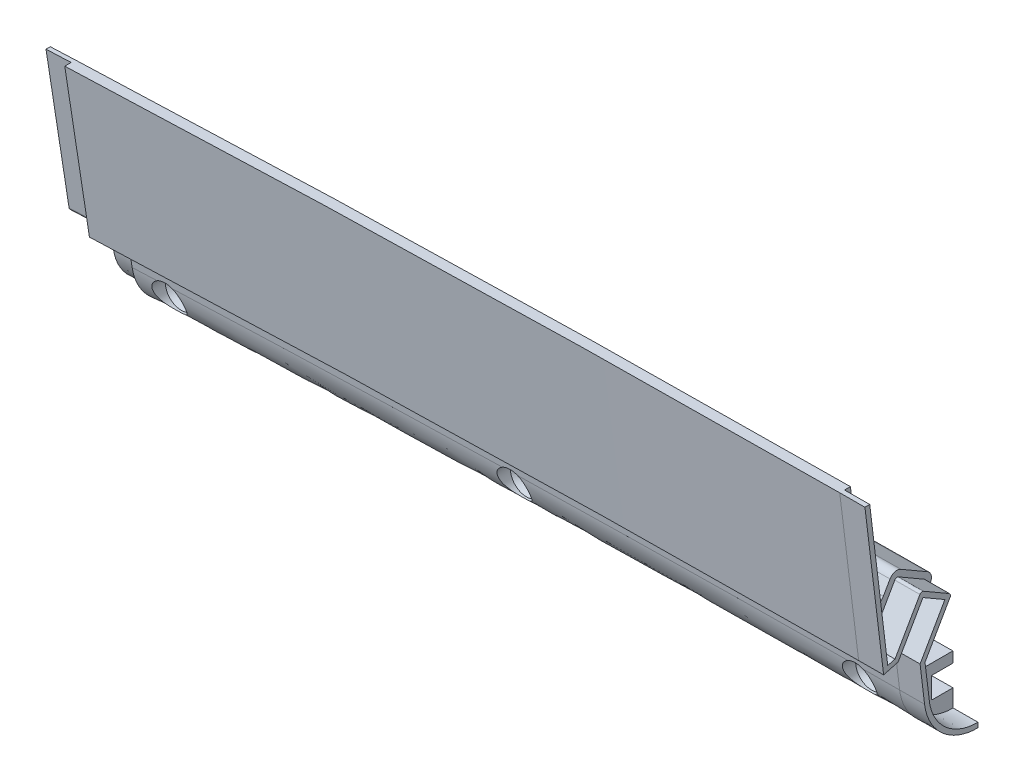
from build123d import *


with BuildPart() as part:
    # Sweep3: sweep along a path in Sketch3
    with BuildLine(Plane.XY.offset(101.6)) as sweep3_path:
        ThreePointArc((622.103936151, -83.199836272), (0, -43.636564626), (-622.103936151, -83.199836272))
    # Sketch4 → Sweep3 (sweep)
    with BuildSketch(Plane(origin=(-117.330566703, 4.430423936, 1117.6), x_dir=(0, 0, -1), z_dir=(0.9994536405585157, 0.03305178322465143, 0))):
        with BuildLine():
            Line((991.529482971, -5.453775083), (988.971801376, -5.453775083))
            Line((988.971801376, -5.453775083), (993.32506615, -42.283775083))
            Line((993.32506615, -42.283775083), (996.794703229, -41.354088728))
            Line((996.794703229, -41.354088728), (1002.763703229, -31.015013775))
            Line((1002.763703229, -31.015013775), (1007.999, -34.037749136))
            Line((1007.999, -34.037749136), (1002.03, -44.376824659))
            Line((1002.03, -44.376824659), (1003.077032208, -53.235049058))
            ThreePointArc((1003.077032208, -53.235049058), (1007.29752688, -61.276835992), (1015.8095, -64.443731312))
            Line((1015.8095, -64.443731312), (1015.8095, -59.12218153))
            Line((1015.8095, -59.12218153), (1010.7295, -59.12218153))
            Line((1010.7295, -59.12218153), (1010.7295, -54.041969025))
            Line((1010.7295, -54.041969025), (1015.8095, -54.041969025))
            Line((1015.8095, -54.041969025), (1015.8095, -51.501969025))
            Line((1015.8095, -51.501969025), (1007.687322123, -51.501969025))
            ThreePointArc((1007.687322123, -51.501969025), (1005.99997215, -50.860507955), (1005.164881483, -49.260118685))
            Line((1005.164881483, -49.260118685), (1004.750455768, -45.75394576))
            ThreePointArc((1004.750455768, -45.75394576), (1004.7850335, -44.943801809), (1005.073167189, -44.18583887))
            Line((1005.073167189, -44.18583887), (1010.516206197, -34.757795418))
            ThreePointArc((1010.516206197, -34.757795418), (1010.706497969, -33.312277166), (1009.818941274, -32.155567572))
            Line((1009.818941274, -32.155567572), (1003.483804566, -28.49781089))
            ThreePointArc((1003.483804566, -28.49781089), (1002.038222268, -28.307482122), (1000.881475684, -29.195102853))
            Line((1000.881475684, -29.195102853), (999.272416391, -31.982200293))
            ThreePointArc((999.272416391, -31.982200293), (996.560692883, -33.200105913), (994.550246564, -31.010392672))
            Line((994.550246564, -31.010392672), (991.529482971, -5.453775083))
        make_face()
    sweep(path=sweep3_path.line)

    # SurfaceCut1
    split(bisect_by=Plane(origin=(-207.689397228, -8.721580716, 0), x_dir=(0.04195640690671103, -0.9991194422687804, 0), z_dir=(-0.9991194422687804, -0.04195640690671103, 0)), keep=Keep.BOTTOM)

    # SurfaceCut2
    split(bisect_by=Plane(origin=(-22.599527872, -0.103088244, 0), x_dir=(-0.00456147456524855, 0.9999895964207781, 0), z_dir=(0.9999895964207781, 0.00456147456524855, 0)), keep=Keep.BOTTOM)

    # Sketch8 → Cut-Revolve1 (revolve, cut)
    with BuildSketch(Plane(origin=(-117.056038996, -3.871025798, 0), x_dir=(0, 0, -1), z_dir=(0.9994536405585157, 0.03305178322465143, 0)), mode=Mode.PRIVATE) as cut_revolve1_sk:
        Polygon((-119.5705, -48.27608749), (-106.8705, -48.27608749), (-106.8705, -46.37108749), (-108.7755, -46.37108749), (-110.6805, -44.46608749), (-119.5705, -44.46608749), align=None)
    cut_revolve1 = revolve(cut_revolve1_sk.sketch.rotate(Axis((-115.460428217, -52.120737191, 119.5705), (0, 0, -1)), 91.894072645), axis=Axis((-115.460428217, -52.120737191, 119.5705), (0, 0, -1)), mode=Mode.SUBTRACT)

    # Sketch-Pattern1: Cut-Revolve1 at 2 more places
    with Locations((82.543476, 1.248991, 0), (-82.510753, -2.638363, 0)):
        add(cut_revolve1, mode=Mode.SUBTRACT)

    # Sweep4: sweep along a path in Sketch12
    with BuildLine(Plane(origin=(0, 0, 101.7905), x_dir=(-1, 0, 0), z_dir=(0, 0, -1))) as sweep4_path:
        ThreePointArc((22.391388502, -45.732457057), (19.406892089, -45.719750506), (16.422388502, -45.708858513))
    # Sketch11 → Sweep4 (sweep)
    with BuildSketch(Plane(origin=(-22.599527872, -0.103088244, 0), x_dir=(0, 0, -1), z_dir=(0.9999895964207782, 0.0045614745652485505, 0))):
        with BuildLine():
            Line((-127.477241199, 0.416291674), (-123.294888708, -34.966157226))
            Line((-123.294888708, -34.966157226), (-121.558436986, -34.500897353))
            Line((-121.558436986, -34.500897353), (-115.572163807, -24.132368061))
            ThreePointArc((-115.572163807, -24.132368061), (-115.18658777, -23.836505161), (-114.704737676, -23.899941929))
            Line((-114.704737676, -23.899941929), (-108.589559095, -27.430541929))
            ThreePointArc((-108.589559095, -27.430541929), (-108.293696195, -27.816117967), (-108.357132963, -28.297968061))
            Line((-108.357132963, -28.297968061), (-114.390345193, -38.747798175))
            Line((-114.390345193, -38.747798175), (-113.38787021, -47.228671998))
            add(Edge.make_bspline(
                [(-113.38787021, -47.228671998), (-113.304795542, -47.931478283), (-113.005394664, -49.331413505), (-111.931567303, -51.922229671), (-109.715936846, -54.745652619), (-106.035083238, -56.94650453), (-103.201893406, -57.441334387), (-101.801323322, -57.428071482)],
                knots=[0, 0, 0, 0, 0.125, 0.25, 0.5, 0.75, 1, 1, 1, 1], degree=3))
            Line((-101.801323322, -57.428071482), (-101.7905, -57.428071482))
            Line((-101.7905, -57.428071482), (-101.7905, -58.571020236))
            add(Edge.make_bspline(
                [(-114.522967792, -47.362845321), (-114.477136038, -47.75057897), (-114.413580033, -48.135193314), (-114.251122313, -48.898201482), (-114.152305696, -49.275575056), (-113.807619255, -50.383408995), (-113.512952594, -51.094578165), (-112.794349261, -52.46234614), (-112.366195112, -53.122316961), (-111.411403795, -54.334839512), (-110.882225451, -54.894118535), (-110.009875034, -55.661739075), (-109.70425095, -55.906767732), (-109.076570448, -56.364164676), (-108.75418736, -56.57709785), (-107.762018779, -57.169725703), (-107.067422067, -57.503632754), (-105.974437358, -57.910210424), (-105.601773783, -58.029584478), (-104.85459633, -58.231768654), (-104.478193263, -58.315333853), (-103.340677537, -58.514298854), (-102.571330027, -58.578414422), (-101.7905, -58.571020236)],
                knots=[0, 0, 0, 0, 0.0625, 0.0625, 0.125, 0.125, 0.25, 0.25, 0.375, 0.375, 0.5, 0.5, 0.5625, 0.5625, 0.625, 0.625, 0.75, 0.75, 0.8125, 0.8125, 0.875, 0.875, 1, 1, 1, 1], degree=3))
            Line((-114.522967792, -47.362845321), (-115.57, -38.505020236))
            Line((-115.57, -38.505020236), (-109.601, -28.166408966))
            Line((-109.601, -28.166408966), (-114.836296771, -25.143808966))
            Line((-114.836296771, -25.143808966), (-120.805296771, -35.482420236))
            Line((-120.805296771, -35.482420236), (-124.27493385, -36.412064801))
            Line((-124.27493385, -36.412064801), (-128.628198624, 0.416291674))
            Line((-128.628198624, 0.416291674), (-127.477241199, 0.416291674))
        make_face()
    sweep(path=sweep4_path.line)

    # Sweep5: sweep along a path in Sketch16
    with BuildLine(Plane(origin=(0, 0, 101.7905), x_dir=(-1, 0, 0), z_dir=(0, 0, -1))) as sweep5_path:
        ThreePointArc((211.919404598, -50.257937623), (208.937647923, -50.129999354), (205.955814013, -50.003873985))
    # Sketch15 → Sweep5 (sweep)
    with BuildSketch(Plane(origin=(-207.689397228, -8.721580716, 0), x_dir=(0, 0, 1), z_dir=(-0.9991194422687804, -0.041956406906711034, 0))):
        with BuildLine():
            Line((113.00950435, -42.87278078), (113.97237291, -34.726974739))
            ThreePointArc((113.97237291, -34.726974739), (113.963727961, -34.524431025), (113.891689273, -34.33493401))
            Line((113.891689273, -34.33493401), (107.519177285, -23.297419473))
            Line((107.519177285, -23.297419473), (115.394119486, -18.750819473))
            Line((115.394119486, -18.750819473), (121.677968823, -29.634765791))
            ThreePointArc((121.677968823, -29.634765791), (121.841334284, -29.821047339), (122.06355177, -29.930630542))
            Line((122.06355177, -29.930630542), (122.259394286, -29.983104022))
            ThreePointArc((122.259394286, -29.983104022), (122.780015415, -29.895373199), (123.054347243, -29.444279966))
            Line((123.054347243, -29.444279966), (127.093588723, 4.727458451))
            Line((127.093588723, 4.727458451), (126.070517029, 4.727458451))
            Line((126.070517029, 4.727458451), (123.049753436, -20.828021292))
            add(Edge.make_bspline(
                [(123.049753436, -20.828021292), (123.018406598, -21.093213611), (122.944898871, -21.352152705), (122.72486191, -21.830474698), (122.574983618, -22.055585814), (122.218479429, -22.443142645), (122.006878086, -22.611118233), (121.662818096, -22.805653471), (121.543504304, -22.86141076), (121.295473201, -22.954456612), (121.166493424, -22.991573845), (120.907997451, -23.044545896), (120.777385583, -23.06088218), (120.51342226, -23.073167247), (120.37910716, -23.068887741), (120.116311005, -23.039783508), (119.986998098, -23.015141306), (119.732512188, -22.945824011), (119.606266969, -22.900611018), (119.243601748, -22.73749278), (119.021351761, -22.592419945), (118.626712377, -22.235700782), (118.461102845, -22.031047533), (118.327583609, -21.799785413)],
                knots=[0, 0, 0, 0, 0.125, 0.125, 0.25, 0.25, 0.375, 0.375, 0.4375, 0.4375, 0.5, 0.5, 0.5625, 0.5625, 0.625, 0.625, 0.6875, 0.6875, 0.75, 0.75, 0.875, 0.875, 1, 1, 1, 1], degree=3))
            Line((118.327583609, -21.799785413), (116.718524316, -19.012812683))
            ThreePointArc((116.718524316, -19.012812683), (115.561765682, -18.125228416), (114.116195434, -18.3155519))
            Line((114.116195434, -18.3155519), (107.781058726, -21.973144929))
            ThreePointArc((107.781058726, -21.973144929), (106.893505265, -23.129790634), (107.083793803, -24.575256201))
            Line((107.083793803, -24.575256201), (112.526832811, -34.002876264))
            ThreePointArc((112.526832811, -34.002876264), (112.814966033, -34.760802836), (112.849544232, -35.570912576))
            Line((112.849544232, -35.570912576), (112.435118517, -39.076927533))
            ThreePointArc((112.435118517, -39.076927533), (111.600006373, -40.677263704), (109.912677877, -41.318676749))
            Line((109.912677877, -41.318676749), (101.7905, -41.318676749))
            Line((101.7905, -41.318676749), (101.7905, -43.858562065))
            Line((101.7905, -43.858562065), (106.8705, -43.858562065))
            Line((106.8705, -43.858562065), (106.8705, -48.938544836))
            Line((106.8705, -48.938544836), (101.7905, -48.938544836))
            Line((101.7905, -48.938544836), (101.7905, -52.735921786))
            Line((101.7905, -52.735921786), (101.804931097, -52.735921786))
            add(Edge.make_bspline(
                [(101.804931097, -52.735921786), (102.489279498, -52.742402325), (103.868868527, -52.626863767), (106.485766193, -51.914547434), (109.465837716, -50.13558786), (112.028433947, -46.874809632), (112.850511097, -44.21785335), (113.00950435, -42.87278078)],
                knots=[0, 0, 0, 0, 0.125, 0.25, 0.5, 0.75, 1, 1, 1, 1], degree=3))
        make_face()
    sweep(path=sweep5_path.line)


solid = part.part
